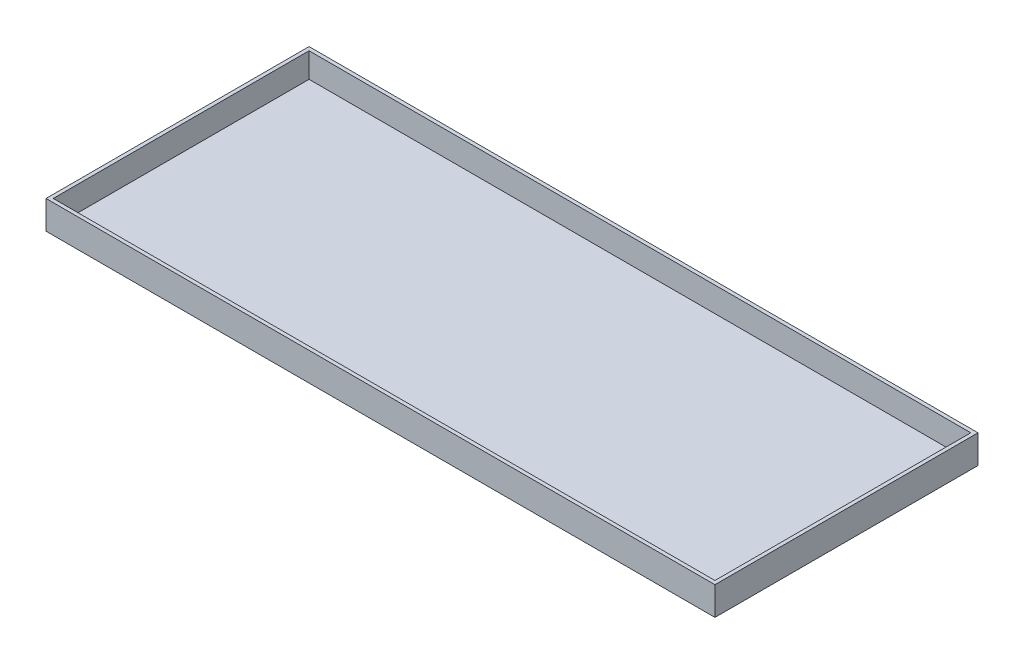
from build123d import *

# Parameters (mm, degrees)
SKETCH1_W           = 70.6628
SKETCH1_H           = 27.7876
BOSS_EXTRUDE1_DEPTH = 2.9972
SHELL1_T            = -0.381


with BuildPart() as part:
    # Sketch1 → Boss-Extrude1 (new body)
    with BuildSketch(Plane(origin=(0, 0, 0), x_dir=(1, 0, 0), z_dir=(0, 1, 0))):
        Rectangle(SKETCH1_W, SKETCH1_H)
    extrude(amount=BOSS_EXTRUDE1_DEPTH)

    # Shell1
    shell1_openings = [part.faces().sort_by_distance(p)[0] for p in [
        (0, 2.9972, 0),
    ]]
    offset(amount=SHELL1_T, openings=shell1_openings, kind=Kind.INTERSECTION)


solid = part.part
